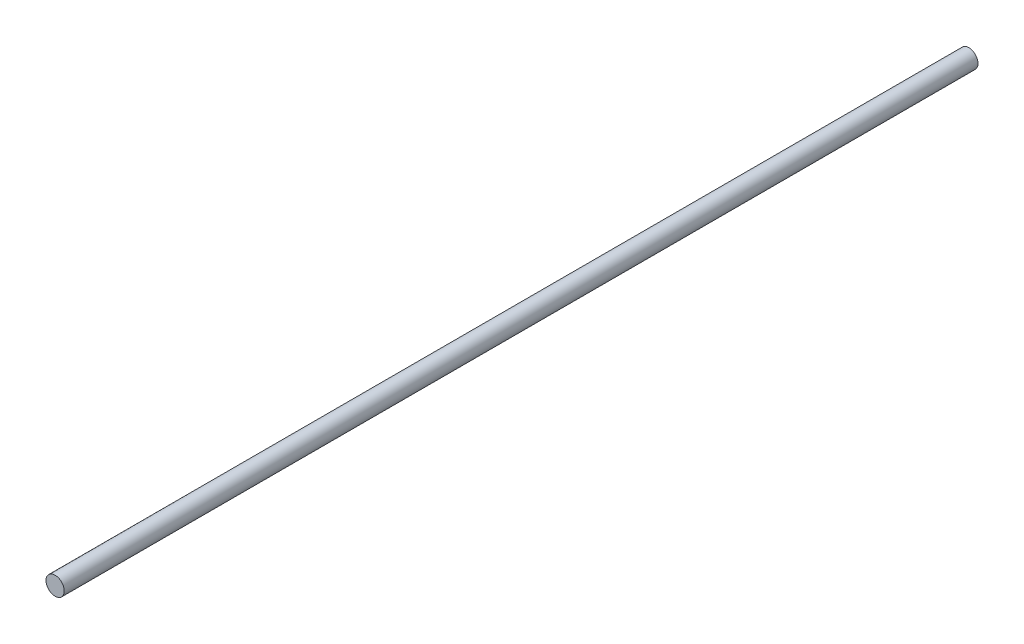
from build123d import *

# Parameters (mm, degrees)
SKETCH1_R           = 1.5
BOSS_EXTRUDE1_DEPTH = 150


with BuildPart() as part:
    # Sketch1 → Boss-Extrude1 (new body)
    with BuildSketch(Plane.XY):
        Circle(SKETCH1_R)
    extrude(amount=BOSS_EXTRUDE1_DEPTH)


solid = part.part
